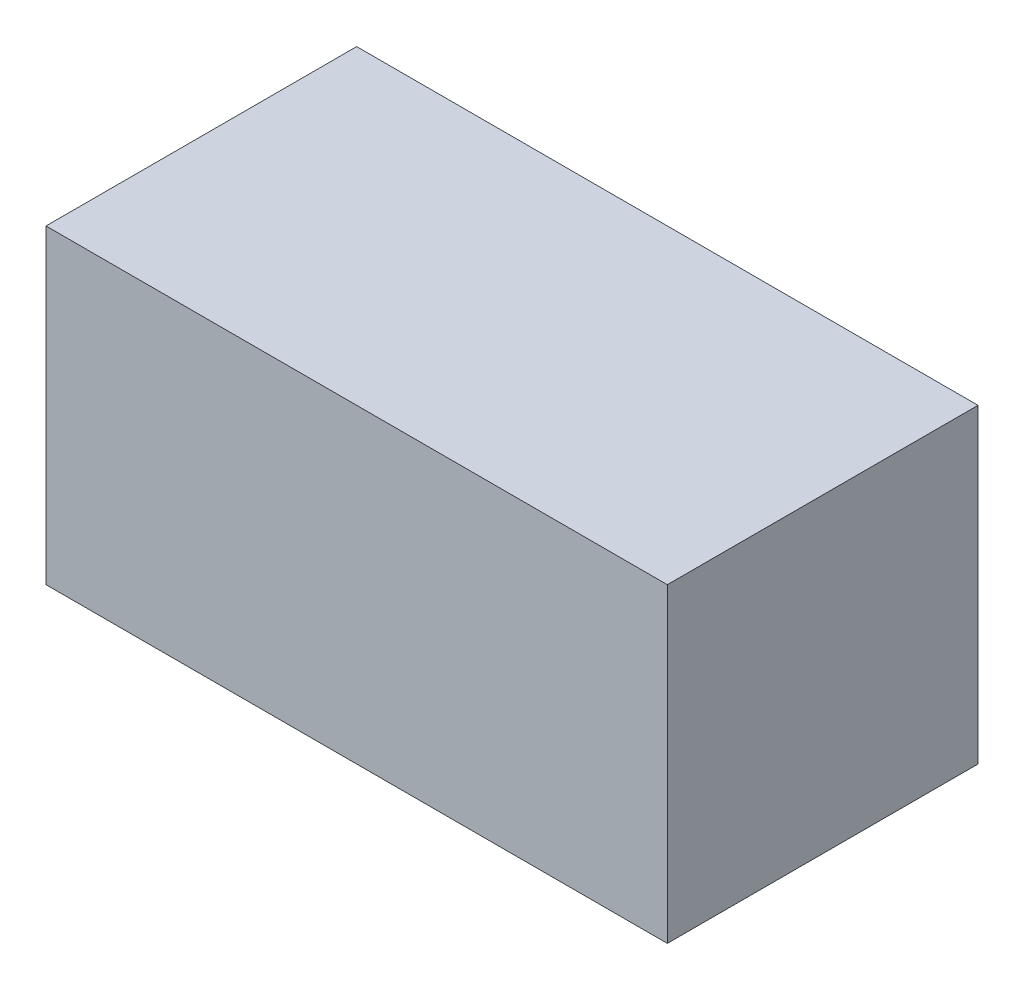
from build123d import *

# Parameters (mm, degrees)
SKETCH1_W                         = 50.8
SKETCH1_H                         = 25.4
BOSS_EXTRUDE1_DEPTH               = 25.4
PIPE_TAP_DRILL_FOR_1_2_TAP1_D     = 17.8562
PIPE_TAP_DRILL_FOR_1_2_TAP1_DEPTH = 38.1
PIPE_TAP_DRILL_FOR_1_2_TAP1_TIP   = 5.364543693


with BuildPart() as part:
    # Sketch1 → Boss-Extrude1 (new body)
    with BuildSketch(Plane(origin=(0, 0, 0), x_dir=(1, 0, 0), z_dir=(0, 1, 0))):
        Rectangle(SKETCH1_W, SKETCH1_H)
    extrude(amount=BOSS_EXTRUDE1_DEPTH)

    # Pipe Tap Drill for 1/2 Tap1
    with Locations(Plane.ZY.offset(25.4)):
        with Locations((0, 12.7)):
            Hole(PIPE_TAP_DRILL_FOR_1_2_TAP1_D / 2, depth=PIPE_TAP_DRILL_FOR_1_2_TAP1_DEPTH)
            with Locations((0, 0, -(PIPE_TAP_DRILL_FOR_1_2_TAP1_DEPTH + PIPE_TAP_DRILL_FOR_1_2_TAP1_TIP / 2))):  # 118° drill point
                Cone(0, PIPE_TAP_DRILL_FOR_1_2_TAP1_D / 2, PIPE_TAP_DRILL_FOR_1_2_TAP1_TIP, mode=Mode.SUBTRACT)

    # Sketch5 → Cut-Revolve2 (revolve, cut)
    with BuildSketch(Plane.XY):
        Polygon((-12.7, -10.766878787), (-9.352189393, -14.114689393), (11.954399011, 7.191899011), (11.1125, 8.033798023), (-0.841899011, -3.920600989), align=None)
    revolve(axis=Axis((-9.352189393, -14.114689393, 0), (0.707106781, 0.707106781, 0)), mode=Mode.SUBTRACT)


solid = part.part
